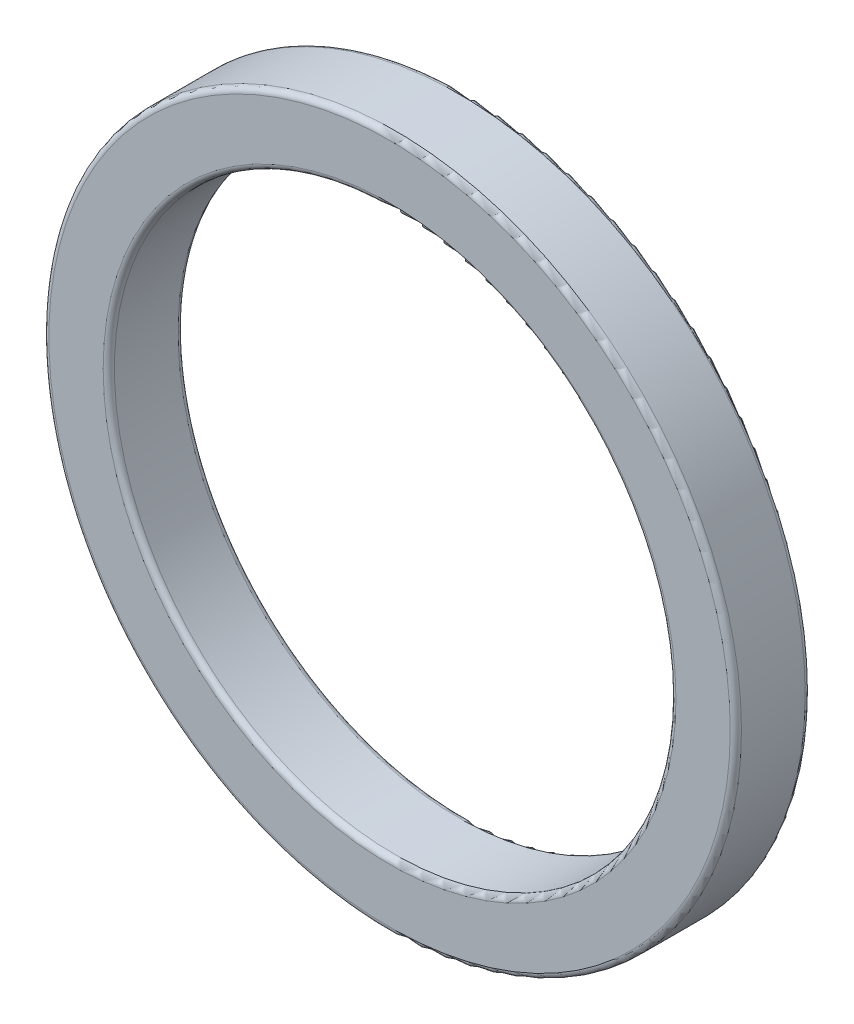
from build123d import *

# Parameters (mm, degrees)
SKETCH_1_R      = 18.5
SKETCH_1_R_2    = 15
EXTRUDE_1_DEPTH = 4
FILLET_1_R      = 0.3


with BuildPart() as part:
    # 草图1 → 凸台-拉伸1 (new body)
    with BuildSketch(Plane.XY):
        Circle(SKETCH_1_R)
        Circle(SKETCH_1_R_2, mode=Mode.SUBTRACT)
    extrude(amount=EXTRUDE_1_DEPTH)

    # 圆角1
    fillet_1_edges = [part.edges().sort_by_distance(p)[0] for p in [
        (-18.5, 0, 0),
        (-18.5, 0, 4),
        (-15, 0, 0),
        (-15, 0, 4),
    ]]
    fillet(fillet_1_edges, radius=FILLET_1_R)


solid = part.part
